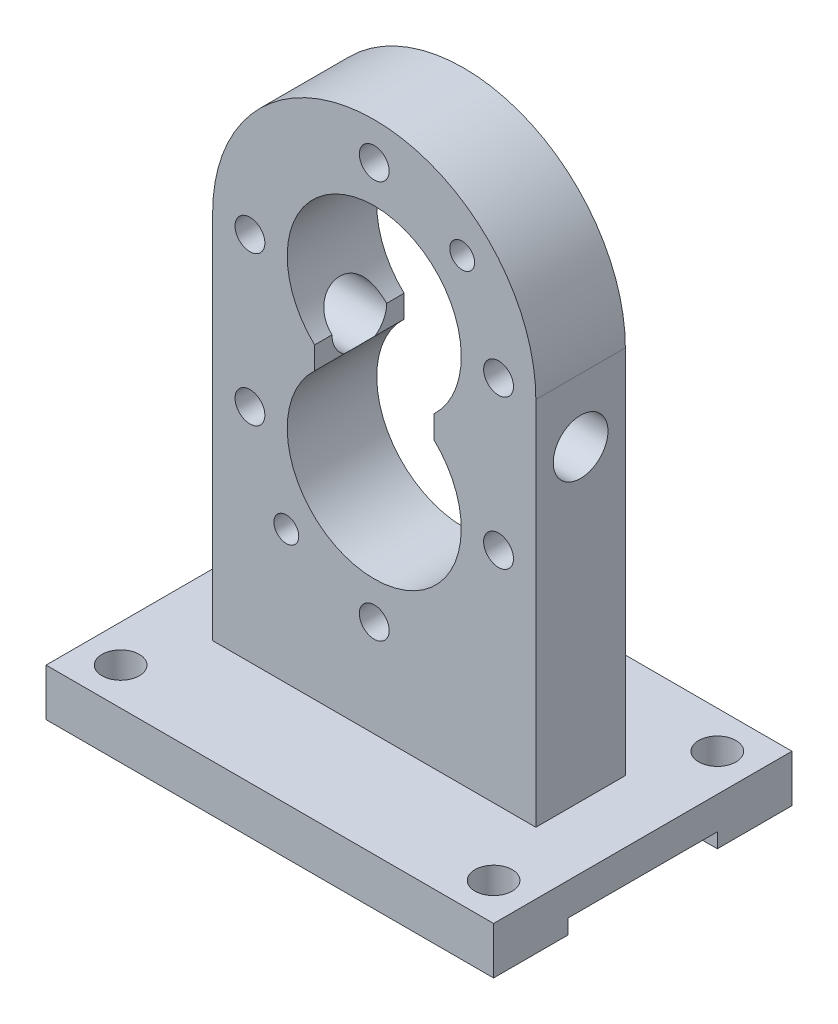
from build123d import *

# Parameters (mm, degrees)
SKETCH2_W           = 180
SKETCH2_H           = 120
SKETCH2_R           = 7.5
BOSS_EXTRUDE1_DEPTH = 9.5
SKETCH14_R          = 6
SKETCH14_R_2        = 5
BOSS_EXTRUDE5_DEPTH = 18
SKETCH16_R          = 9
CUT_EXTRUDE6_DEPTH  = 156
SKETCH18_R          = 11
CUT_EXTRUDE7_DEPTH  = 156
SKETCH19_W          = 60
SKETCH19_H          = 11.842550856
CUT_EXTRUDE8_DEPTH  = 181


with BuildPart() as part:
    # Sketch2 → Boss-Extrude1 (new body, symmetric)
    with BuildSketch(Plane(origin=(0, 0, 0), x_dir=(1, 0, 0), z_dir=(0, 1, 0))):
        Rectangle(SKETCH2_W, SKETCH2_H)
        with Locations((-75, 45)):
            Circle(SKETCH2_R, mode=Mode.SUBTRACT)
        with Locations((75, 45)):
            Circle(SKETCH2_R, mode=Mode.SUBTRACT)
        with Locations((75, -45)):
            Circle(SKETCH2_R, mode=Mode.SUBTRACT)
        with Locations((-75, -45)):
            Circle(SKETCH2_R, mode=Mode.SUBTRACT)
    extrude(amount=BOSS_EXTRUDE1_DEPTH, both=True)

    # Sketch14 → Boss-Extrude5 (add, symmetric)
    with BuildSketch(Plane.XY):
        with BuildLine():
            Line((-65, 9.5), (-65, 158.5))
            ThreePointArc((-65, 158.5), (0, 223.5), (65, 158.5))
            Line((65, 158.5), (65, 9.5))
            Line((65, 9.5), (-65, 9.5))
        make_face()
        with Locations((0, 208.5)):
            Circle(SKETCH14_R, mode=Mode.SUBTRACT)
        with Locations((0, 48.5)):
            Circle(SKETCH14_R, mode=Mode.SUBTRACT)
        with Locations((-50, 158.5)):
            Circle(SKETCH14_R, mode=Mode.SUBTRACT)
        with Locations((-50, 98.5)):
            Circle(SKETCH14_R, mode=Mode.SUBTRACT)
        with Locations((50, 98.5)):
            Circle(SKETCH14_R, mode=Mode.SUBTRACT)
        with Locations((50, 158.5)):
            Circle(SKETCH14_R, mode=Mode.SUBTRACT)
        with Locations((-35.36, 63.14)):
            Circle(SKETCH14_R_2, mode=Mode.SUBTRACT)
        with Locations((35.36, 193.86)):
            Circle(SKETCH14_R_2, mode=Mode.SUBTRACT)
        with BuildLine():
            Line((-24, 133.024521594), (-24, 123.975478406))
            ThreePointArc((-24, 123.975478406), (0, 63.5), (24, 123.975478406))
            Line((24, 123.975478406), (24, 133.024521594))
            ThreePointArc((24, 133.024521594), (0, 193.5), (-24, 133.024521594))
        make_face(mode=Mode.SUBTRACT)
    extrude(amount=BOSS_EXTRUDE5_DEPTH, both=True)

    # Sketch16 → Cut-Extrude6 (cut, through all)
    with BuildSketch(Plane(origin=(65, 0, 0), x_dir=(0, 0, -1), z_dir=(1, 0, 0))):
        with Locations((0, 133.024521594)):
            Circle(SKETCH16_R)
    extrude(amount=-CUT_EXTRUDE6_DEPTH, mode=Mode.SUBTRACT)

    # Sketch18 → Cut-Extrude7 (cut, through all)
    with BuildSketch(Plane(origin=(65, 0, 0), x_dir=(0, 0, -1), z_dir=(1, 0, 0))):
        with Locations((0, 133.024521594)):
            Circle(SKETCH18_R)
    extrude(amount=-CUT_EXTRUDE7_DEPTH, mode=Mode.SUBTRACT)

    # Sketch19 → Cut-Extrude8 (cut, through all)
    with BuildSketch(Plane(origin=(90, 0, 0), x_dir=(0, 0, -1), z_dir=(1, 0, 0))):
        with Locations((0, -9.5)):
            Rectangle(SKETCH19_W, SKETCH19_H)
    extrude(amount=-CUT_EXTRUDE8_DEPTH, mode=Mode.SUBTRACT)


solid = part.part
